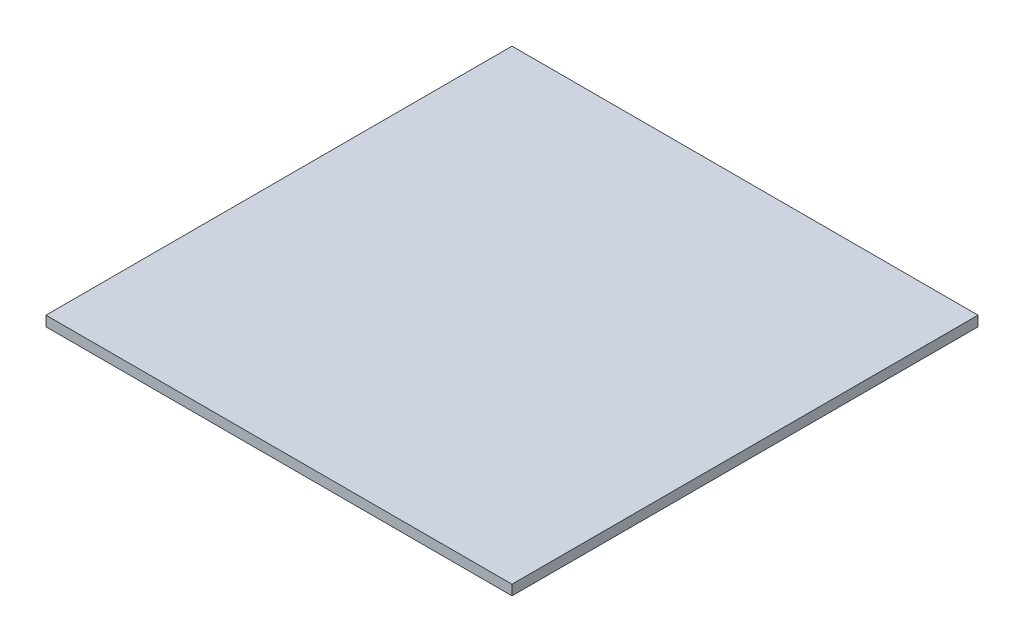
from build123d import *

# Parameters (mm, degrees)
SKETCH1_W           = 46
SKETCH1_H           = 46
BOSS_EXTRUDE1_DEPTH = 1


with BuildPart() as part:
    # Sketch1 → Boss-Extrude1 (new body)
    with BuildSketch(Plane(origin=(0, 0, 0), x_dir=(1, 0, 0), z_dir=(0, 1, 0))):
        Rectangle(SKETCH1_W, SKETCH1_H)
    extrude(amount=BOSS_EXTRUDE1_DEPTH)


solid = part.part
